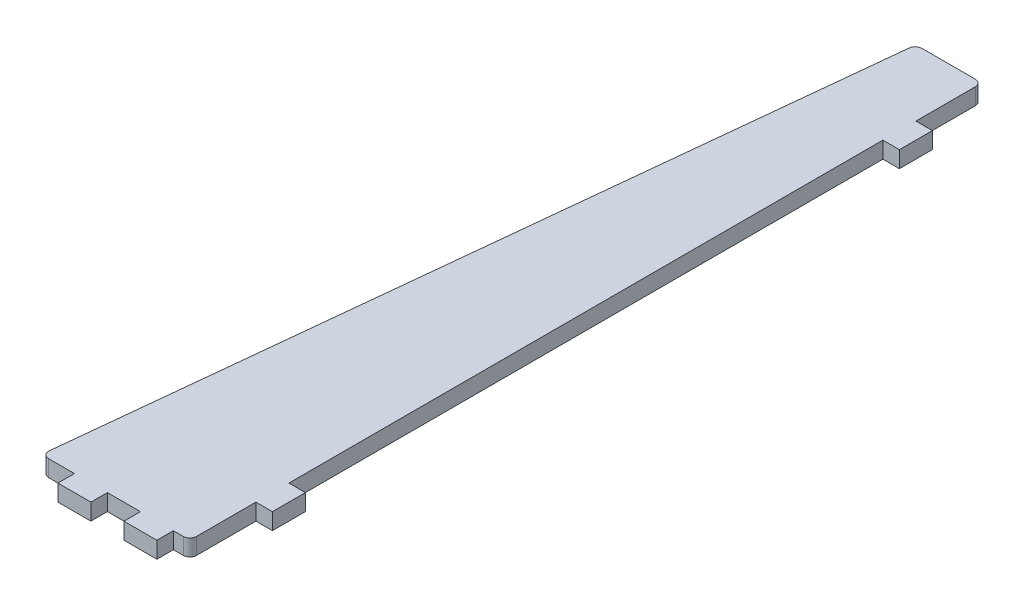
from build123d import *

# Parameters (mm, degrees)
SIDE_PLATE_DEPTH = 6.35
FILLET1_R        = 2.54


with BuildPart() as part:
    # Sketch1 → Side Plate (new body)
    with BuildSketch(Plane(origin=(0, 0, 0), x_dir=(1, 0, 0), z_dir=(0, 1, 0))):
        Polygon((0, 0), (12.7, 0), (12.7, -6.35), (25.4, -6.35), (25.4, 0), (38.1, 0), (38.1, -6.35), (50.8, -6.35), (50.8, 0), (57.15, 0), (57.15, 25.4), (63.5, 25.4), (63.5, 38.1), (57.15, 38.1), (57.15, 266.7), (63.5, 266.7), (63.5, 279.4), (57.15, 279.4), (57.15, 304.8), (31.75, 304.8), align=None)
    extrude(amount=SIDE_PLATE_DEPTH)

    # Fillet1
    fillet1_edges = [part.edges().sort_by_distance(p)[0] for p in [
        (31.75, 3.175, -304.8),
        (57.15, 3.175, -304.8),
        (57.15, 3.175, 0),
        (0, 3.175, 0),
    ]]
    fillet(fillet1_edges, radius=FILLET1_R)


solid = part.part
